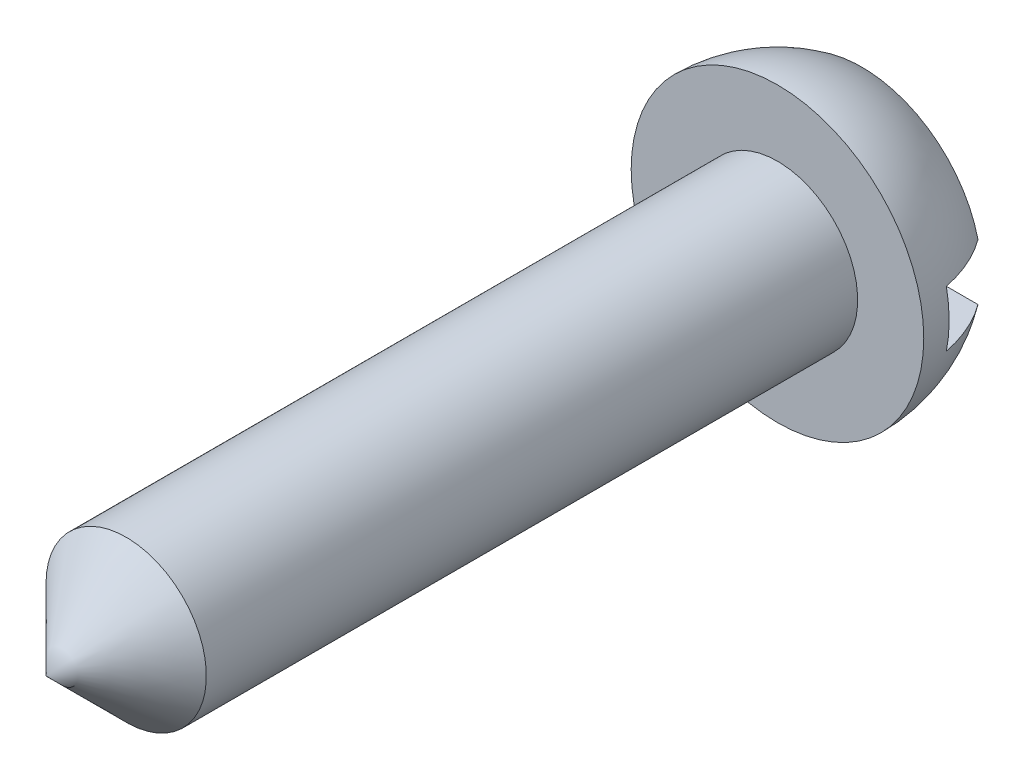
from build123d import *

# Parameters (mm, degrees)
ESBO_O2_W             = 5.89486681
ESBO_O2_H             = 1
CORTE_EXTRUS_O1_DEPTH = 1


with BuildPart() as part:
    # Esboço1 → Revolução1 (revolve)
    with BuildSketch(Plane(origin=(0, 0, 0), x_dir=(1, 0, 0), z_dir=(0, 1, 0))):
        with BuildLine():
            Line((0, 0), (0, 1.5))
            Line((0, 1.5), (2.123676058, 1.5))
            ThreePointArc((2.123676058, 1.5), (2.478059498, 0.786906045), (2.6, 0))
            Line((2.6, 0), (1.425, 0))
            Line((1.425, 0), (1.425, -11.575))
            Line((1.425, -11.575), (0, -13))
            Line((0, -13), (0, 0))
        make_face()
    revolve(axis=Axis((0, 0, 0), (0, 0, 1)))

    # Esboço2 → Corte-extrusão1 (cut)
    with BuildSketch(Plane(origin=(0, 0, -1.5), x_dir=(-1, 0, 0), z_dir=(0, 0, -1))):
        Rectangle(ESBO_O2_W, ESBO_O2_H)
    extrude(amount=-CORTE_EXTRUS_O1_DEPTH, mode=Mode.SUBTRACT)


solid = part.part
